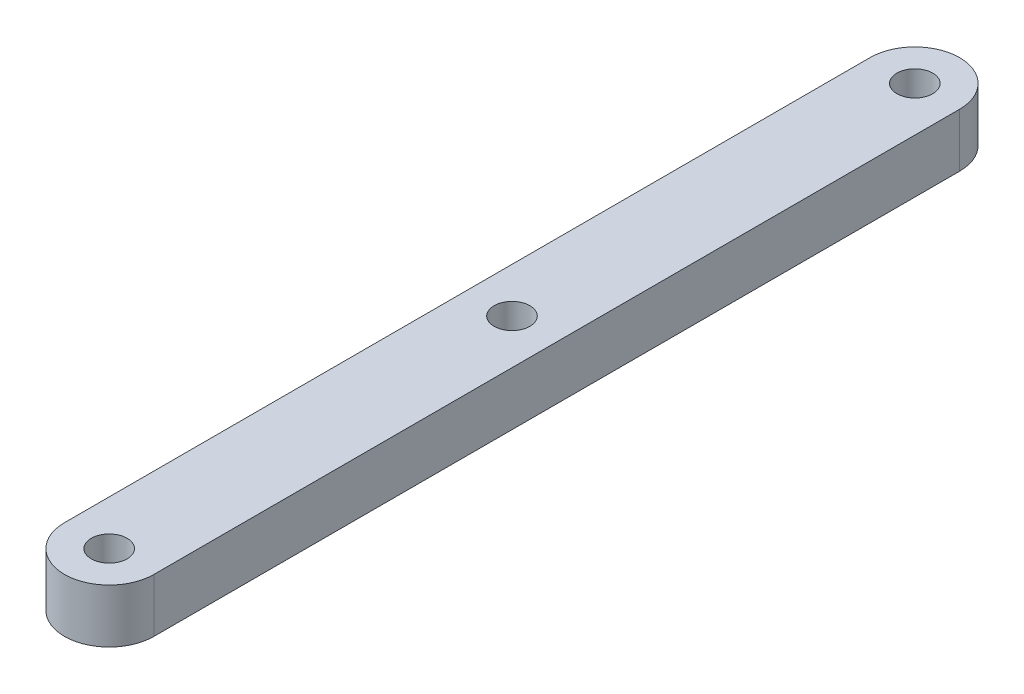
from build123d import *

# Parameters (mm, degrees)
SKETCH1_R           = 1
BOSS_EXTRUDE1_DEPTH = 3


with BuildPart() as part:
    # Sketch1 → Boss-Extrude1 (new body)
    with BuildSketch(Plane(origin=(0, 0, 0), x_dir=(1, 0, 0), z_dir=(0, 1, 0))):
        with BuildLine():
            Line((2.5, 22.5), (2.5, -22.5))
            ThreePointArc((2.5, -22.5), (0, -25), (-2.5, -22.5))
            Line((-2.5, -22.5), (-2.5, 22.5))
            ThreePointArc((-2.5, 22.5), (0, 25), (2.5, 22.5))
        make_face()
        with Locations((0, 22.5)):
            Circle(SKETCH1_R, mode=Mode.SUBTRACT)
        with Locations((0, -22.5)):
            Circle(SKETCH1_R, mode=Mode.SUBTRACT)
        Circle(SKETCH1_R, mode=Mode.SUBTRACT)
    extrude(amount=BOSS_EXTRUDE1_DEPTH)


solid = part.part
